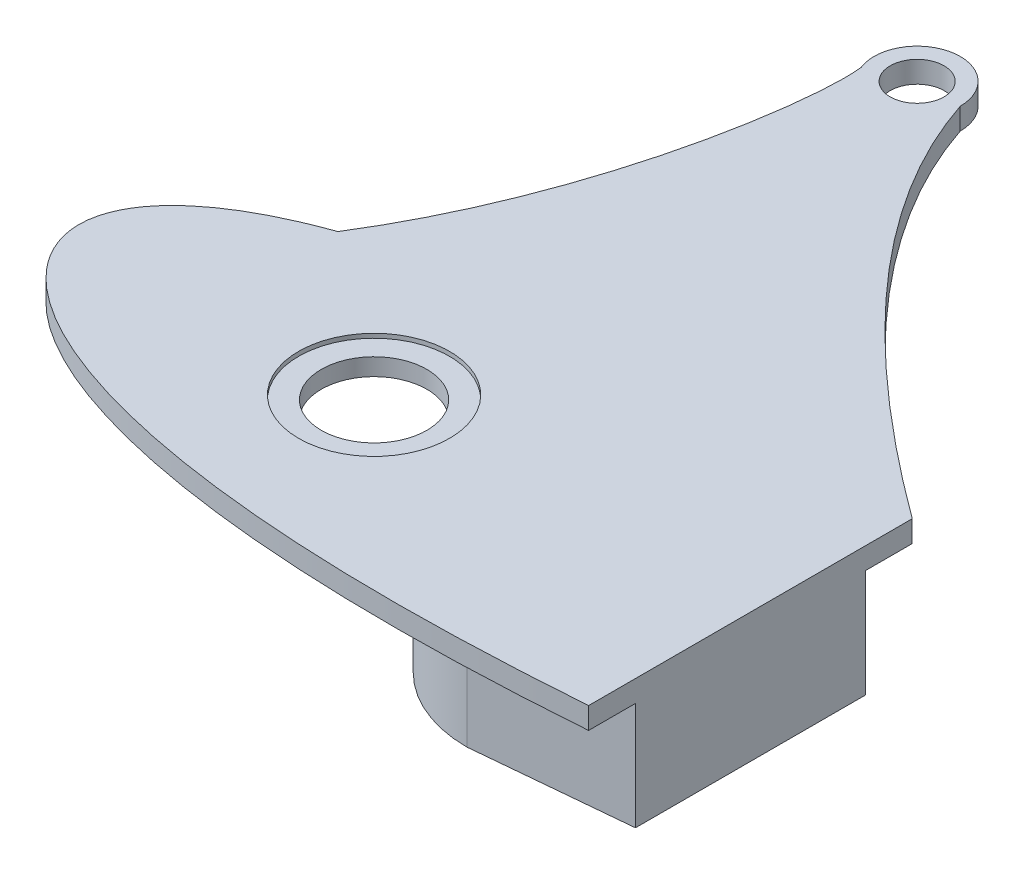
from build123d import *

# Parameters (mm, degrees)
SKETCH1_R           = 6.223
SKETCH1_R_2         = 3.175
BOSS_EXTRUDE1_DEPTH = 2.54
SKETCH1_3_R         = 4.233333333
BOSS_EXTRUDE2_DEPTH = 12.7
SKETCH2_R           = 8.89
CUT_EXTRUDE2_DEPTH  = 0.508


with BuildPart() as part:
    # Sketch1 → Boss-Extrude1 (new body)
    with BuildSketch(Plane(origin=(0, 0, 0), x_dir=(1, 0, 0), z_dir=(0, 1, 0))):
        with BuildLine():
            add(Edge.make_bspline(
                [(-106.608177043, 0), (-106.607181853, 0.336221439), (-106.553109217, 1.172470844), (-106.231145111, 2.643099261), (-105.439203383, 4.475217401), (-104.022724766, 6.504348411), (-101.933239026, 8.571651325), (-99.191911488, 10.567556696), (-95.844996836, 12.426747292), (-92.90409582, 13.696332592), (-91.099565345, 14.363844596), (-90.622228407, 14.533411548)],
                knots=[0.5, 0.5, 0.5, 0.5, 0.502166769, 0.505390167, 0.509655974, 0.514947682, 0.521244711, 0.528520886, 0.536744945, 0.54588136, 0.54914681, 0.54914681, 0.54914681, 0.54914681], degree=3))
            add(Edge.make_bspline(
                [(-106.608177043, 0), (-106.607181853, -0.336221439), (-106.553109217, -1.172470844), (-106.231145111, -2.643099261), (-105.439203383, -4.475217401), (-104.022724766, -6.504348411), (-101.933239026, -8.571651325), (-99.191911488, -10.567556696), (-95.844996836, -12.426747292), (-91.942526077, -14.111441704), (-87.531895483, -15.599318155), (-82.657100659, -16.877133316), (-77.359343302, -17.937435613), (-71.677800746, -18.776740565), (-65.650341253, -19.395460579), (-59.313785065, -19.796574023), (-52.704246728, -19.986276309), (-45.857195612, -19.97286583), (-38.807557342, -19.767322463), (-32.659211886, -19.439565325), (-28.865800162, -19.174037811), (-27.479757553, -19.069204536)],
                knots=[0.5, 0.5, 0.5, 0.5, 0.502166769, 0.505390167, 0.509655974, 0.514947682, 0.521244711, 0.528520886, 0.536744945, 0.54588136, 0.555890751, 0.566730119, 0.57835299, 0.590709588, 0.603747039, 0.617409572, 0.631638768, 0.646373793, 0.661551658, 0.677107483, 0.686069724, 0.686069724, 0.686069724, 0.686069724], degree=3))
            Line((-27.479757553, -19.069204536), (-27.479757553, 19.069204536))
            add(Edge.make_bspline(
                [(-66.748032241, 63.994278454), (-59.662783709, 42.677267871), (-27.479757553, 19.069204536)],
                knots=[0, 0, 0, 1, 1, 1], degree=2))
            ThreePointArc((-66.748032241, 63.994278454), (-72.773341431, 68.985549888), (-76.556217491, 62.136682092))
            add(Edge.make_bspline(
                [(-90.622228407, 14.533411548), (-78.676623194, 33.624035256), (-75.814032891, 56.696401983), (-76.556217491, 62.136682092)],
                knots=[0, 0, 0, 0, 1, 1, 1, 1], degree=3))
        make_face()
        with Locations((-71.828032241, 0)):
            Circle(SKETCH1_R, mode=Mode.SUBTRACT)
        with Locations((-71.828032241, 63.994278454)):
            Circle(SKETCH1_R_2, mode=Mode.SUBTRACT)
    extrude(amount=BOSS_EXTRUDE1_DEPTH)

    # Sketch1_3 → Boss-Extrude2 (add)
    with BuildSketch(Plane(origin=(0, 0, 0), x_dir=(1, 0, 0), z_dir=(0, 1, 0))):
        with Locations((-93.062306932, 0)):
            Circle(SKETCH1_3_R)
        with BuildLine():
            Line((-45.666032241, -15.24), (-27.479757553, -13.544433585))
            Line((-27.479757553, -13.544433585), (-27.479757553, 13.544433585))
            Line((-27.479757553, 13.544433585), (-45.666032241, 15.24))
            ThreePointArc((-45.666032241, 15.24), (-60.906032241, 0), (-45.666032241, -15.24))
        make_face()
    extrude(amount=-BOSS_EXTRUDE2_DEPTH)

    # Sketch2 → Cut-Extrude2 (cut)
    with BuildSketch(Plane(origin=(0, 2.54, 0), x_dir=(1, 0, 0), z_dir=(0, 1, 0))):
        with Locations((-71.828032241, 0)):
            Circle(SKETCH2_R)
    extrude(amount=-CUT_EXTRUDE2_DEPTH, mode=Mode.SUBTRACT)


solid = part.part
